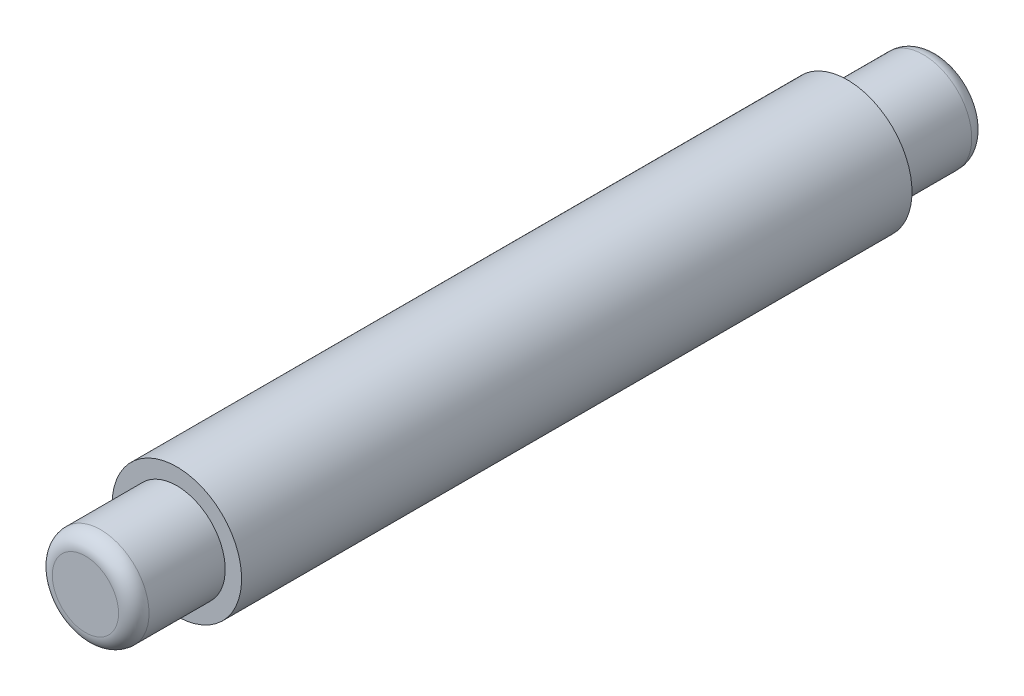
from build123d import *

# Parameters (mm, degrees)
SKETCH1_R           = 3.175
BOSS_EXTRUDE1_DEPTH = 6
SKETCH2_R           = 4.25
BOSS_EXTRUDE2_DEPTH = 44
SKETCH3_R           = 3.175
BOSS_EXTRUDE3_DEPTH = 6
FILLET1_R           = 1


with BuildPart() as part:
    # Sketch1 → Boss-Extrude1 (new body)
    with BuildSketch(Plane.XY):
        Circle(SKETCH1_R)
    extrude(amount=BOSS_EXTRUDE1_DEPTH)

    # Sketch2 → Boss-Extrude2 (add)
    with BuildSketch(Plane(origin=(0, 0, 0), x_dir=(-1, 0, 0), z_dir=(0, 0, -1))):
        Circle(SKETCH2_R)
    extrude(amount=BOSS_EXTRUDE2_DEPTH)

    # Sketch3 → Boss-Extrude3 (add)
    with BuildSketch(Plane(origin=(0, 0, -44), x_dir=(-1, 0, 0), z_dir=(0, 0, -1))):
        Circle(SKETCH3_R)
    extrude(amount=BOSS_EXTRUDE3_DEPTH)

    # Fillet1
    fillet1_edges = [part.edges().sort_by_distance(p)[0] for p in [
        (3.175, 0, -50),
        (-3.175, 0, 6),
    ]]
    fillet(fillet1_edges, radius=FILLET1_R)


solid = part.part
